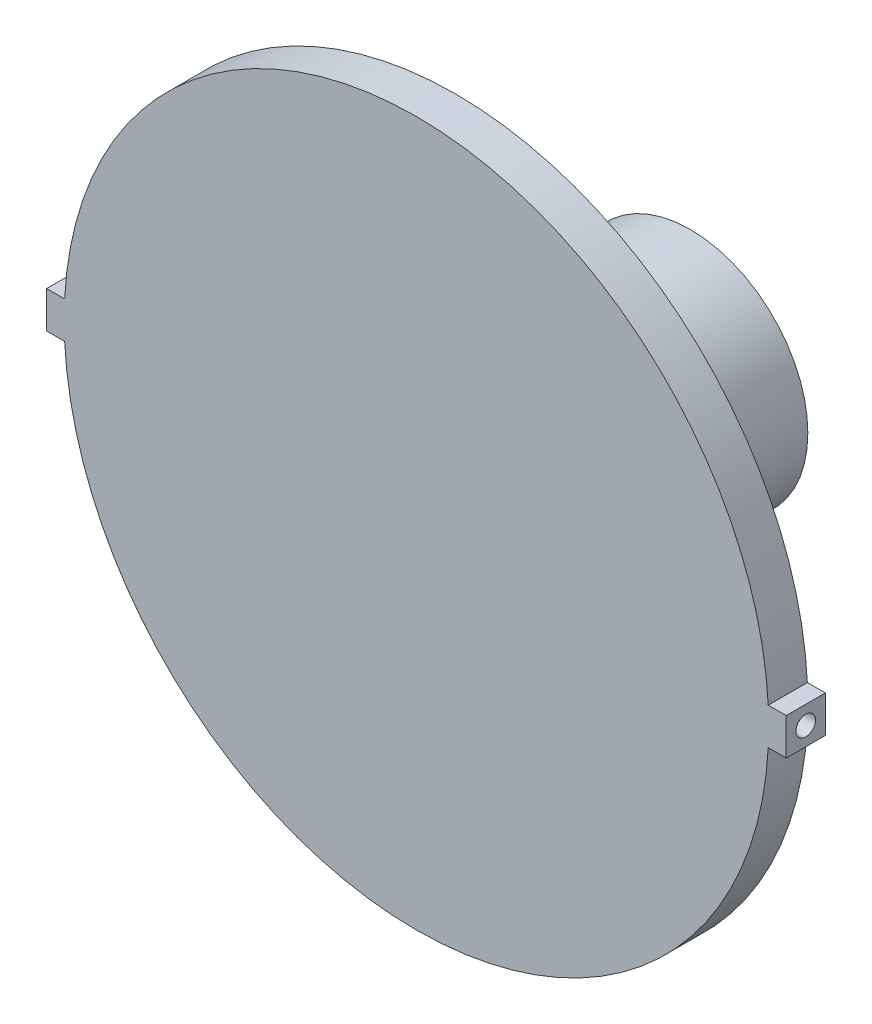
from build123d import *

# Parameters (mm, degrees)
BOSS_EXTRUDE2_DEPTH = 5
SKETCH6_R           = 15
BOSS_EXTRUDE3_DEPTH = 30
SKETCH7_R           = 4
BOSS_EXTRUDE4_DEPTH = 6.9
SKETCH8_R           = 1.25
CUT_EXTRUDE1_DEPTH  = 5
SKETCH9_R           = 1.25
CUT_EXTRUDE2_DEPTH  = 5


with BuildPart() as part:
    # Sketch5 → Boss-Extrude2 (new body)
    with BuildSketch(Plane.XY):
        with BuildLine():
            Line((-44.938485198, 2.352136924), (-47.238485198, 2.352136924))
            Line((-47.238485198, 2.352136924), (-47.238485198, -2.352136924))
            Line((-47.238485198, -2.352136924), (-44.938485198, -2.352136924))
            ThreePointArc((-44.938485198, -2.352136924), (0, -45), (44.938485198, -2.352136924))
            Line((44.938485198, -2.352136924), (47.238485198, -2.352136924))
            Line((47.238485198, -2.352136924), (47.238485198, 2.352136924))
            Line((47.238485198, 2.352136924), (44.938485198, 2.352136924))
            ThreePointArc((44.938485198, 2.352136924), (0, 45), (-44.938485198, 2.352136924))
        make_face()
    extrude(amount=BOSS_EXTRUDE2_DEPTH)

    # Sketch6 → Boss-Extrude3 (add)
    with BuildSketch(Plane(origin=(0, 0, 0), x_dir=(-1, 0, 0), z_dir=(0, 0, -1))):
        Circle(SKETCH6_R)
    extrude(amount=BOSS_EXTRUDE3_DEPTH)

    # Sketch7 → Boss-Extrude4 (add)
    with BuildSketch(Plane(origin=(0, 0, -30), x_dir=(-1, 0, 0), z_dir=(0, 0, -1))):
        Circle(SKETCH7_R)
    extrude(amount=BOSS_EXTRUDE4_DEPTH)

    # Sketch8 → Cut-Extrude1 (cut)
    with BuildSketch(Plane(origin=(47.238485198, 0, 0), x_dir=(0, 0, -1), z_dir=(1, 0, 0))):
        with Locations((-2.5, 0)):
            Circle(SKETCH8_R)
    extrude(amount=-CUT_EXTRUDE1_DEPTH, mode=Mode.SUBTRACT)

    # Sketch9 → Cut-Extrude2 (cut)
    with BuildSketch(Plane.ZY.offset(47.238485198)):
        with Locations((2.5, 0)):
            Circle(SKETCH9_R)
    extrude(amount=-CUT_EXTRUDE2_DEPTH, mode=Mode.SUBTRACT)


solid = part.part
